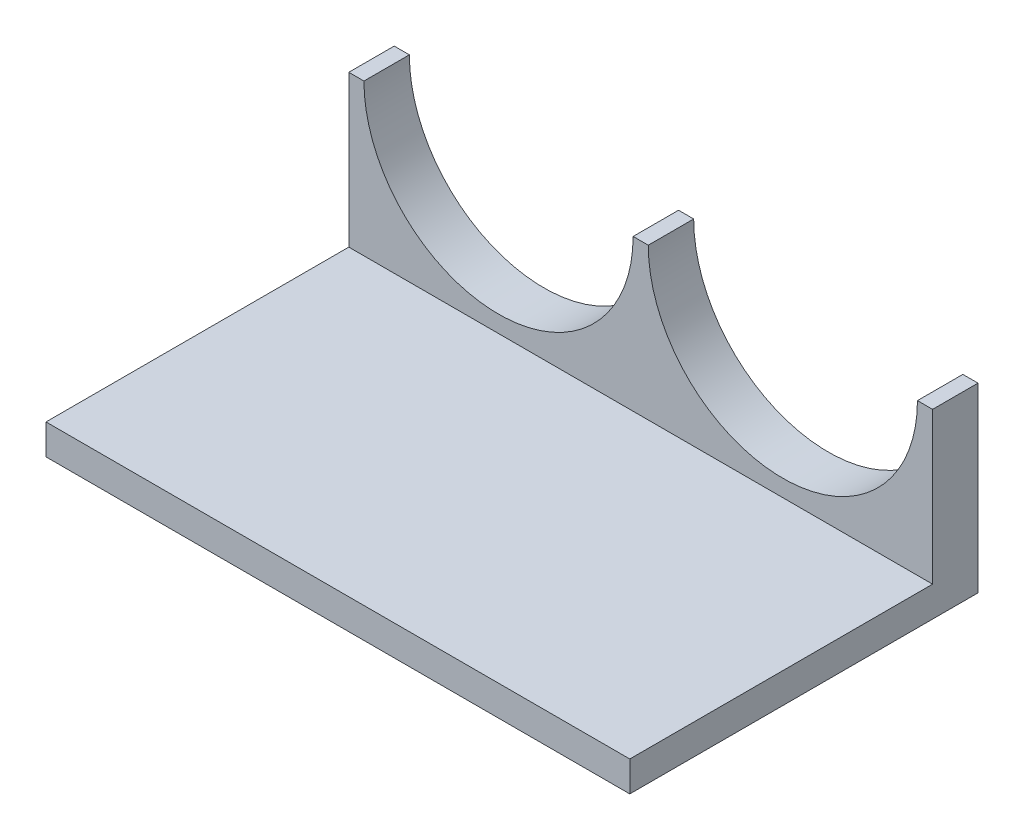
from build123d import *

# Parameters (mm, degrees)
BOSS_EXTRUDE2_DEPTH = 15
SKETCH8_W           = 192.8
SKETCH8_H           = 10
BOSS_EXTRUDE3_DEPTH = 100


with BuildPart() as part:
    # Sketch7 → Boss-Extrude2 (new body)
    with BuildSketch(Plane.XY):
        with BuildLine():
            Line((0, 10), (0, 60))
            Line((0, 60), (5, 60))
            ThreePointArc((5, 60), (49.45, 15.55), (93.9, 60))
            Line((93.9, 60), (98.9, 60))
            ThreePointArc((98.9, 60), (143.35, 15.55), (187.8, 60))
            Line((187.8, 60), (192.8, 60))
            Line((192.8, 60), (192.8, 0))
            Line((192.8, 0), (0, 0))
            Line((0, 0), (0, 10))
        make_face()
    extrude(amount=BOSS_EXTRUDE2_DEPTH)

    # Sketch8 → Boss-Extrude3 (add)
    with BuildSketch(Plane.XY.offset(15)):
        with Locations((96.4, 5)):
            Rectangle(SKETCH8_W, SKETCH8_H)
    extrude(amount=BOSS_EXTRUDE3_DEPTH)


solid = part.part
